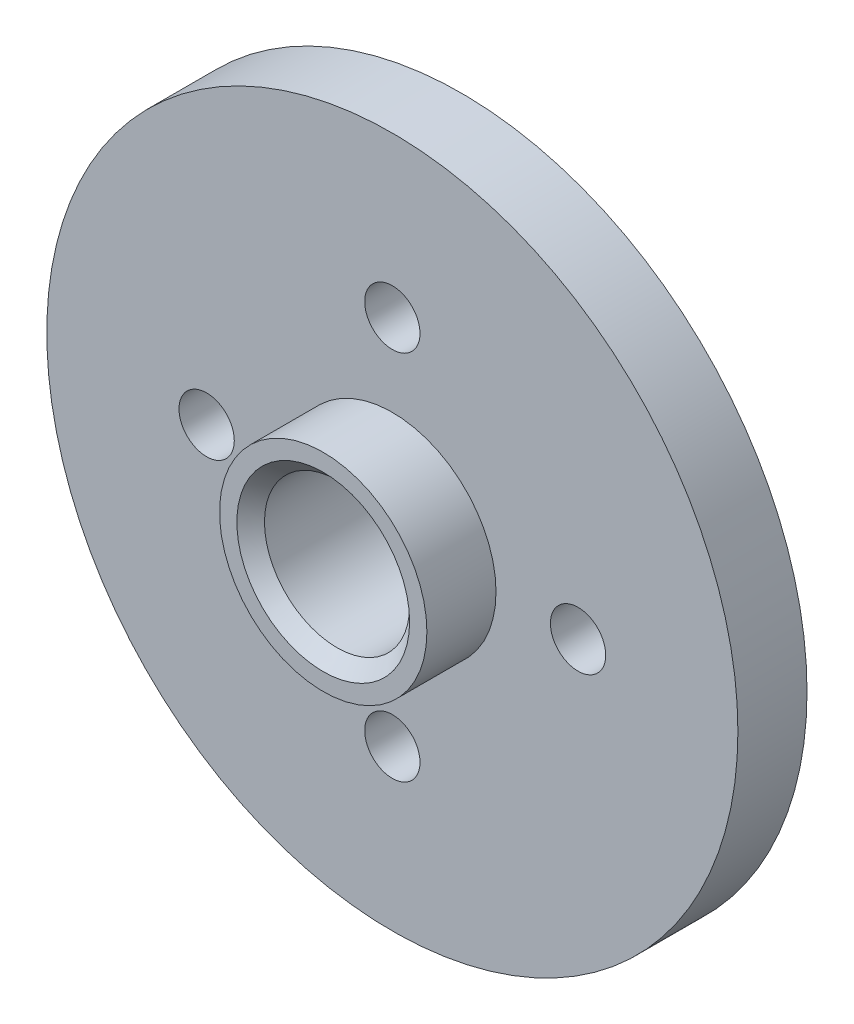
from build123d import *

# Parameters (mm, degrees)
SCHIZZO1_R                       = 50
SCHIZZO1_R_2                     = 4
ESTRUSIONE_ESTRUSIONE1_DEPTH     = 10
SCHIZZO2_R                       = 15
ESTRUSIONE_ESTRUSIONE2_DEPTH     = 10
FORO_FILETTATO_M24_1_D           = 21
FORO_FILETTATO_M24_1_CSINK_D     = 24.05
FORO_FILETTATO_M24_1_CSINK_ANGLE = 120
SMUSSO1_SIZE                     = 2


with BuildPart() as part:
    # Schizzo1 → Estrusione-Estrusione1 (new body)
    with BuildSketch(Plane.XY):
        Circle(SCHIZZO1_R)
        with Locations((0, 26.870057685)):
            Circle(SCHIZZO1_R_2, mode=Mode.SUBTRACT)
        with Locations((26.870057685, 0)):
            Circle(SCHIZZO1_R_2, mode=Mode.SUBTRACT)
        with Locations((0, -26.870057685)):
            Circle(SCHIZZO1_R_2, mode=Mode.SUBTRACT)
        with Locations((-26.870057685, 0)):
            Circle(SCHIZZO1_R_2, mode=Mode.SUBTRACT)
    extrude(amount=ESTRUSIONE_ESTRUSIONE1_DEPTH)

    # Schizzo2 → Estrusione-Estrusione2 (add)
    with BuildSketch(Plane.XY.offset(10)):
        Circle(SCHIZZO2_R)
    extrude(amount=ESTRUSIONE_ESTRUSIONE2_DEPTH)

    # Foro filettato M24-1 (through all)
    with Locations(Plane(origin=(0, 0, 0), x_dir=(-1, 0, 0), z_dir=(0, 0, -1))):
        with Locations((0, 0)):
            CounterSinkHole(FORO_FILETTATO_M24_1_D / 2, FORO_FILETTATO_M24_1_CSINK_D / 2, counter_sink_angle=FORO_FILETTATO_M24_1_CSINK_ANGLE)

    # Smusso1
    smusso1_edges = [part.edges().sort_by_distance(p)[0] for p in [
        (-10.5, 0, 20),
    ]]
    chamfer(smusso1_edges, length=SMUSSO1_SIZE)


solid = part.part
